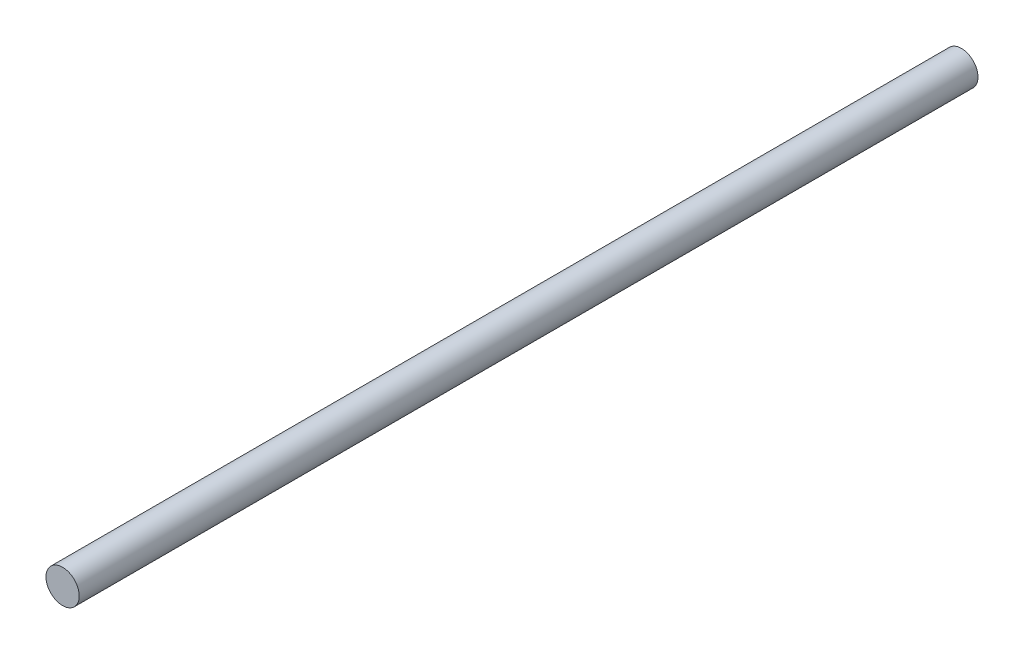
from build123d import *

# Parameters (mm, degrees)
ESBO_O1_R                = 4
RESSALTO_EXTRUS_O1_DEPTH = 108.115


with BuildPart() as part:
    # Esboço1 → Ressalto-extrusão1 (new body, symmetric)
    with BuildSketch(Plane.XY):
        Circle(ESBO_O1_R)
    extrude(amount=RESSALTO_EXTRUS_O1_DEPTH, both=True)


solid = part.part
